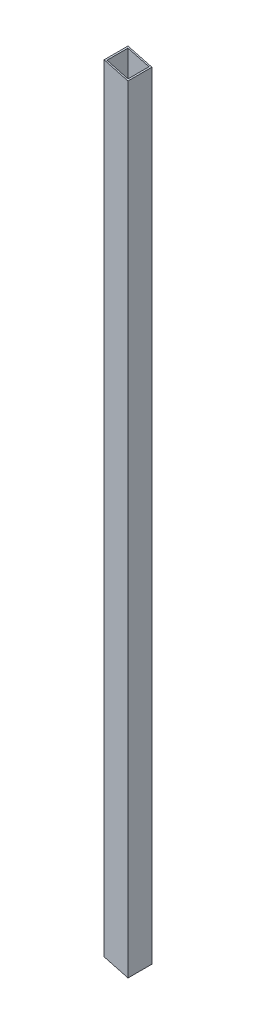
from build123d import *

# Parameters (mm, degrees)
SKETCH1_W               = 25.4
SKETCH1_H               = 25.4
SKETCH1_W_2             = 22.352
SKETCH1_H_2             = 22.352
BOSS_EXTRUDE1_DEPTH     = 877.062
CUT_EXTRUDE1_DEPTH      = 1
CUT_EXTRUDE1_DEPTH_BACK = 26.4
CUT_EXTRUDE2_DEPTH      = 1
CUT_EXTRUDE2_DEPTH_BACK = 26.4


with BuildPart() as part:
    # Sketch1 → Boss-Extrude1 (new body)
    with BuildSketch(Plane(origin=(0, 0, 0), x_dir=(1, 0, 0), z_dir=(0, 1, 0))):
        with Locations((-12.7, 4.695189487)):
            Rectangle(SKETCH1_W, SKETCH1_H)
        with Locations((-12.7, 4.695189487)):
            Rectangle(SKETCH1_W_2, SKETCH1_H_2, mode=Mode.SUBTRACT)
    extrude(amount=BOSS_EXTRUDE1_DEPTH)

    # Sketch2 → Cut-Extrude1 (cut, two sides)
    with BuildSketch(Plane.XY.offset(8.004810513)) as cut_extrude1_sk:
        Polygon((-25.4, 877.062), (0, 870.256090512), (0, 877.062), align=None)
    extrude(amount=CUT_EXTRUDE1_DEPTH, mode=Mode.SUBTRACT)
    extrude(cut_extrude1_sk.sketch, amount=-CUT_EXTRUDE1_DEPTH_BACK, mode=Mode.SUBTRACT)

    # Sketch3 → Cut-Extrude2 (cut, two sides)
    with BuildSketch(Plane(origin=(0, 0, -17.395189487), x_dir=(-1, 0, 0), z_dir=(0, 0, -1))) as cut_extrude2_sk:
        Polygon((25.4, 0), (25.4, 50.8), (0, 43.994090512), (0, 0), align=None)
    extrude(amount=CUT_EXTRUDE2_DEPTH, mode=Mode.SUBTRACT)
    extrude(cut_extrude2_sk.sketch, amount=-CUT_EXTRUDE2_DEPTH_BACK, mode=Mode.SUBTRACT)


solid = part.part
